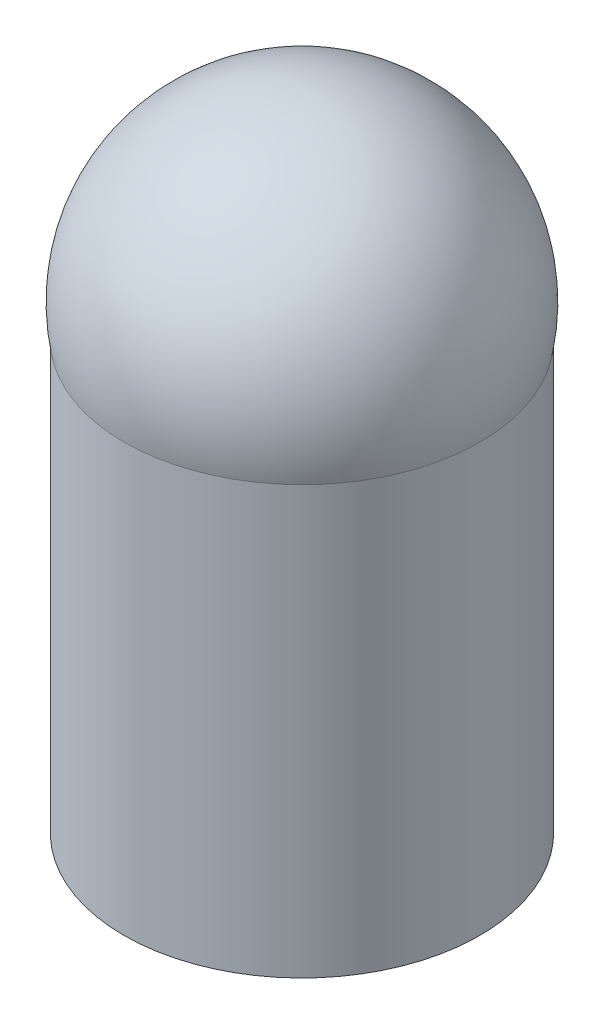
from build123d import *

# Parameters (mm, degrees)
SKETCH1_R           = 2.5
BOSS_EXTRUDE1_DEPTH = 6
DOME2_FACE_RADIUS   = 2.5
DOME2_HEIGHT        = 3


with BuildPart() as part:
    # Sketch1 → Boss-Extrude1 (new body)
    with BuildSketch(Plane(origin=(0, 0, 0), x_dir=(1, 0, 0), z_dir=(0, 1, 0))):
        with Locations((-23.304673918, 11.259801097)):
            Circle(SKETCH1_R)
    extrude(amount=BOSS_EXTRUDE1_DEPTH)

    # Dome2: a dome of height H over a round flat face of radius A is a cap of a sphere of radius (A * A + H * H) / (2 * H)
    dome2_r = (DOME2_FACE_RADIUS * DOME2_FACE_RADIUS + DOME2_HEIGHT * DOME2_HEIGHT) / (2 * DOME2_HEIGHT)
    dome2_base = Plane((-23.304673918, 6, -11.259801097), z_dir=(0, 1, 0))
    with Locations(dome2_base.offset(DOME2_HEIGHT - dome2_r)):
        dome2_ball = Sphere(dome2_r, mode=Mode.PRIVATE)
    add(split(dome2_ball, bisect_by=dome2_base, keep=Keep.TOP, mode=Mode.PRIVATE))


solid = part.part
